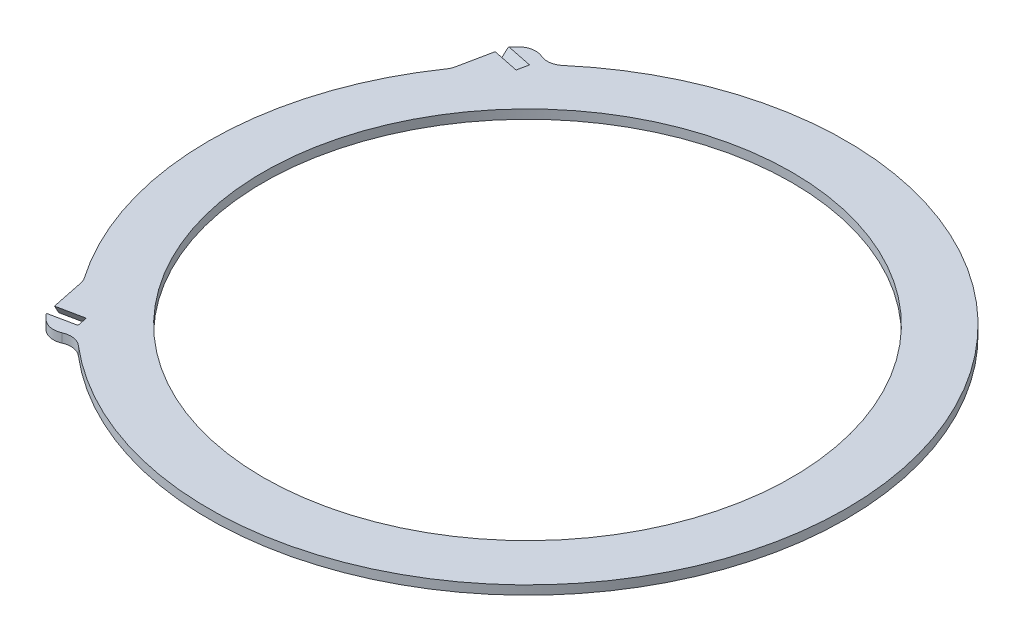
from build123d import *

# Parameters (mm, degrees)
SKETCH1_R            = 355.5
SKETCH1_R_2          = 295
BOSS_EXTRUDE1_DEPTH  = 10
BOSS_EXTRUDE2_DEPTH  = 10
FILLET1_R            = 20
CUT_EXTRUDE2_DEPTH   = 10
FILLET1_OF_MIRROR1_R = 20
CUT_EXTRUDE3_DEPTH   = 10


with BuildPart() as part:
    # Sketch1 → Boss-Extrude1 (new body)
    with BuildSketch(Plane(origin=(0, 0, 0), x_dir=(1, 0, 0), z_dir=(0, 1, 0))):
        with Locations(Location((0, 0, 0), (0, 0, 270))):
            Circle(SKETCH1_R)
        with Locations(Location((0, 0, 0), (0, 0, 270))):
            Circle(SKETCH1_R_2, mode=Mode.SUBTRACT)
    extrude(amount=BOSS_EXTRUDE1_DEPTH)

    # Sketch2 → Boss-Extrude2 (add)
    with BuildSketch(Plane(origin=(0, 10, 0), x_dir=(1, 0, 0), z_dir=(0, 1, 0))):
        with BuildLine():
            Line((-245.283583567, -262.746957418), (-201.307169156, -215.639568833))
            ThreePointArc((-201.307169156, -215.639568833), (-222.262433031, -193.970128791), (-240.896902392, -170.27531359))
            Line((-240.896902392, -170.27531359), (-290.301182374, -205.196182987))
            Line((-290.301182374, -205.196182987), (-281.950699468, -245.840512698))
            Line((-281.950699468, -245.840512698), (-279.584698805, -257.356554597))
            ThreePointArc((-279.584698805, -257.356554597), (-276.977549571, -260.160406353), (-274.342282872, -262.937847843))
            ThreePointArc((-274.342282872, -262.937847843), (-259.771835552, -269.098582225), (-245.283583567, -262.746957418))
        make_face()
    boss_extrude2 = extrude(amount=-BOSS_EXTRUDE2_DEPTH)

    # Fillet1
    fillet1_edges = [part.edges().sort_by_distance(p)[0] for p in [
        (-242.592198763, 5, 259.863954983),
        (-290.301182374, 5, 205.196182987),
    ]]
    fillet(fillet1_edges, radius=FILLET1_R)

    # Sketch5 → Cut-Extrude2 (cut)
    with BuildSketch(Plane(origin=(27.612671151, -84.821098534, 134.399234523), x_dir=(0.9852397845422893, 0.0913606537099085, -0.14476117541924585), z_dir=(0.17117992567781853, -0.5258335661753164, 0.8331845496216823))):
        Polygon((-283.235912451, 130.899924333), (-284.869220227, 115.781445421), (-336.691704543, 117.064133397), (-330.542349464, 147.835610422), (-311.799599221, 145.810758591), (-281.973151258, 142.588492009), align=None)
    extrude(amount=-CUT_EXTRUDE2_DEPTH, mode=Mode.SUBTRACT)

    # Mirror1: Boss-Extrude2 across plane
    add(boss_extrude2.mirror(Plane.XY))

    # Fillet1 of Mirror1
    fillet1_of_mirror1_edges = [part.edges().sort_by_distance(p)[0] for p in [
        (-242.592198763, 5, -259.863954983),
        (-290.301182374, 5, -205.196182987),
    ]]
    fillet(fillet1_of_mirror1_edges, radius=FILLET1_OF_MIRROR1_R)

    # Sketch7 → Cut-Extrude3 (cut)
    with BuildSketch(Plane(origin=(21.951425264, -85.580716552, -106.844235968), x_dir=(0.9873859847265816, 0.0989832733999036, 0.12357681316719149), z_dir=(-0.1583316682332344, 0.6172782613106412, 0.7706481888305408))):
        Polygon((-278.02290676, 157.72118356), (-276.013481271, 173.565711271), (-305.775097923, 177.340121727), (-307.784523411, 161.495594016), (-310.409727388, 140.795589263), (-280.648110736, 137.021178806), align=None)
    extrude(amount=-CUT_EXTRUDE3_DEPTH, mode=Mode.SUBTRACT)


solid = part.part
